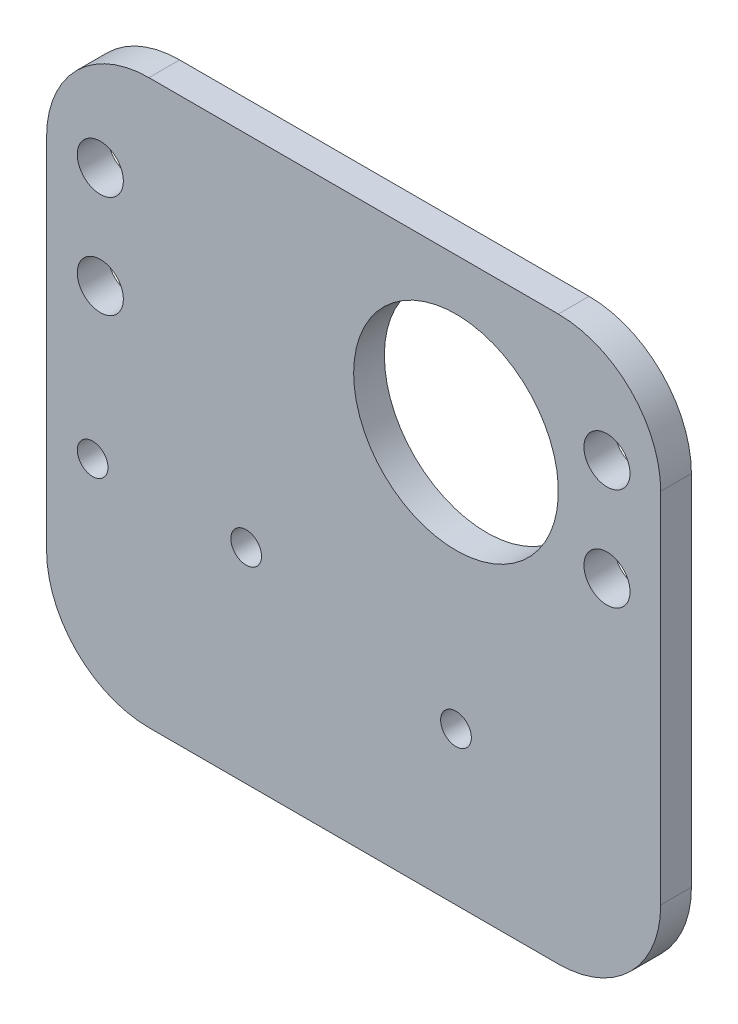
from build123d import *

# Parameters (mm, degrees)
SKETCH_3_R               = 3
EXTRUDE_6_DEPTH          = 0.001
EXTRUDE_6_2_DEPTH        = 0.001
EXTRUDE_6_3_DEPTH        = 0.001
EXTRUDE_6_4_DEPTH        = 0.001
SKETCH_11_R              = 2.25
CUT_EXTRUDE_2_DEPTH      = 1
CUT_EXTRUDE_2_DEPTH_BACK = 1.001
EXTRUDE_7_DEPTH          = 3
SKETCH_14_R              = 2.25
SKETCH_14_R_2            = 10
CUT_EXTRUDE_3_DEPTH      = 3
SKETCH_15_R              = 10
SKETCH_15_R_2            = 1.5
CUT_EXTRUDE_4_DEPTH      = 3
SKETCH_16_R              = 1.5
CUT_EXTRUDE_5_DEPTH      = 10
SKETCH_17_R              = 7.5
SKETCH_17_R_2            = 5.5
EXTRUDE_8_DEPTH          = 7
FILLET_1_R               = 10


with BuildPart() as part:
    # 草图3 → 凸台-拉伸6 (new body)
    with BuildSketch(Plane.XY):
        with Locations((60.266478541, 16.532501821)):
            Circle(SKETCH_3_R)
    extrude(amount=EXTRUDE_6_DEPTH)


with BuildPart() as body_2:
    # 草图3 → Extrude 6 2 (new body)
    with BuildSketch(Plane.XY):
        with Locations((60.266478541, 6.532501821)):
            Circle(SKETCH_3_R)
    extrude(amount=EXTRUDE_6_2_DEPTH)


with BuildPart() as body_3:
    # 草图3 → Extrude 6 3 (new body)
    with BuildSketch(Plane.XY):
        with Locations((10.766478541, 6.532501821)):
            Circle(SKETCH_3_R)
    extrude(amount=EXTRUDE_6_3_DEPTH)


with BuildPart() as body_4:
    # 草图3 → Extrude 6 4 (new body)
    with BuildSketch(Plane.XY):
        with Locations((10.766478541, 16.532501821)):
            Circle(SKETCH_3_R)
    extrude(amount=EXTRUDE_6_4_DEPTH)


with BuildPart() as cut_extrude_2_tool:
    # 草图11 → 切除-拉伸2 (new body, two sides)
    with BuildSketch(Plane.XY.offset(0.001)) as cut_extrude_2_sk:
        with Locations((10.766478541, 16.532501821)):
            Circle(SKETCH_11_R)
        with Locations((10.766478541, 6.532501821)):
            Circle(SKETCH_11_R)
        with Locations((60.266478541, 16.532501821)):
            Circle(SKETCH_11_R)
        with Locations((60.266478541, 6.532501821)):
            Circle(SKETCH_11_R)
    extrude(amount=CUT_EXTRUDE_2_DEPTH)
    extrude(cut_extrude_2_sk.sketch, amount=-CUT_EXTRUDE_2_DEPTH_BACK)


with BuildPart() as part_1:
    add(part.part)

    # 切除-拉伸2: cut by cut_extrude_2_tool
    add(cut_extrude_2_tool.part, mode=Mode.SUBTRACT)



with BuildPart() as body_2_1:
    add(body_2.part)

    # 切除-拉伸2: cut by cut_extrude_2_tool
    add(cut_extrude_2_tool.part, mode=Mode.SUBTRACT)


with BuildPart() as body_3_1:
    add(body_3.part)

    # 切除-拉伸2: cut by cut_extrude_2_tool
    add(cut_extrude_2_tool.part, mode=Mode.SUBTRACT)


with BuildPart() as body_4_1:
    add(body_4.part)

    # 切除-拉伸2: cut by cut_extrude_2_tool
    add(cut_extrude_2_tool.part, mode=Mode.SUBTRACT)


with BuildPart() as part_2:
    add(part_1.part)

    add(body_2_1.part)  # 凸台-拉伸7 merges body 2

    add(body_3_1.part)  # 凸台-拉伸7 merges body 3

    add(body_4_1.part)  # 凸台-拉伸7 merges body 4
    # 草图12 → 凸台-拉伸7 (add)
    with BuildSketch(Plane.XY.offset(0.001)):
        Polygon((5.516478541, 26.532501821), (65.516478541, 26.532501821), (65.516478541, -28.467498179), (5.516478541, -28.467498179), (5.516478541, 1.532501821), align=None)
    extrude(amount=EXTRUDE_7_DEPTH)

    # 草图14 → 切除-拉伸3 (cut)
    with BuildSketch(Plane(origin=(0, 0, 0.001), x_dir=(-1, 0, 0), z_dir=(0, 0, -1))):
        with Locations((-60.266478541, 6.532501821)):
            Circle(SKETCH_14_R)
        with Locations((-60.266478541, 16.532501821)):
            Circle(SKETCH_14_R)
        with Locations((-10.766478541, 6.532501821)):
            Circle(SKETCH_14_R)
        with Locations((-10.766478541, 16.532501821)):
            Circle(SKETCH_14_R)
        with Locations((-45.516478541, 11.532501821)):
            Circle(SKETCH_14_R_2)
    extrude(amount=-CUT_EXTRUDE_3_DEPTH, mode=Mode.SUBTRACT)

    # 草图15 → 切除-拉伸4 (cut)
    with BuildSketch(Plane(origin=(0, 0, 0.001), x_dir=(-1, 0, 0), z_dir=(0, 0, -1))):
        with Locations((-45.516478541, 11.532501821)):
            Circle(SKETCH_15_R)
        with Locations((-45.516478541, -13.567498179)):
            Circle(SKETCH_15_R_2)
    extrude(amount=-CUT_EXTRUDE_4_DEPTH, mode=Mode.SUBTRACT)

    # 草图16 → 切除-拉伸5 (cut)
    with BuildSketch(Plane.XY.offset(3.001)):
        with Locations((10.016478541, -8.467498179)):
            Circle(SKETCH_16_R)
        with Locations((25.016478541, -8.467498179)):
            Circle(SKETCH_16_R)
    extrude(amount=-CUT_EXTRUDE_5_DEPTH, mode=Mode.SUBTRACT)

    # 草图17 → 凸台-拉伸8 (add)
    with BuildSketch(Plane.XY.offset(3.001)):
        with Locations((45.516478541, -13.567498179)):
            Circle(SKETCH_17_R)
        with Locations((45.516478541, -13.567498179)):
            Circle(SKETCH_17_R_2, mode=Mode.SUBTRACT)
    extrude(amount=-EXTRUDE_8_DEPTH)

    # 圆角1
    fillet_1_edges = [part_2.edges().sort_by_distance(p)[0] for p in [
        (5.516478541, 26.532501821, 1.501),
        (5.516478541, -28.467498179, 1.501),
        (65.516478541, -28.467498179, 1.501),
        (65.516478541, 26.532501821, 1.501),
    ]]
    fillet(fillet_1_edges, radius=FILLET_1_R)


solid = part_2.part
